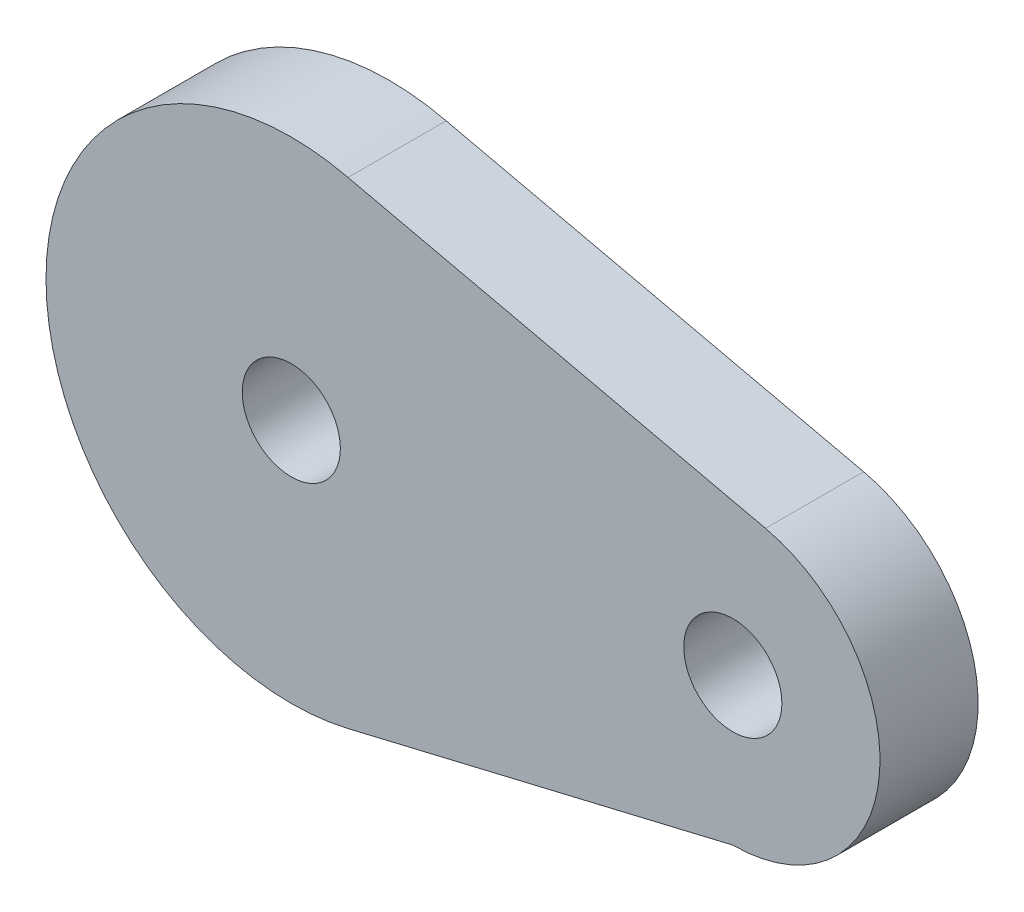
from build123d import *

# Parameters (mm, degrees)
SKETCH2_R           = 60
SKETCH2_R_2         = 5
BOSS_EXTRUDE1_DEPTH = 10
SKETCH3_R           = 5
CUT_EXTRUDE1_DEPTH  = 32
SKETCH4_R           = 81.078971207
CUT_EXTRUDE2_DEPTH  = 130


with BuildPart() as part:
    # Sketch2 → Boss-Extrude1 (new body)
    with BuildSketch(Plane.XY):
        Circle(SKETCH2_R)
        Circle(SKETCH2_R_2, mode=Mode.SUBTRACT)
    extrude(amount=BOSS_EXTRUDE1_DEPTH)

    # Sketch3 → Cut-Extrude1 (cut)
    with BuildSketch(Plane.XY.offset(10)):
        with Locations((45, 0)):
            Circle(SKETCH3_R)
    extrude(amount=-CUT_EXTRUDE1_DEPTH, mode=Mode.SUBTRACT)

    # Sketch4 → Cut-Extrude2 (cut)
    with BuildSketch(Plane(origin=(0, 0, 0), x_dir=(-1, 0, 0), z_dir=(0, 0, -1))):
        Circle(SKETCH4_R)
        with BuildLine():
            Line((-5.781451877, -24.322311037), (-45, -15))
            ThreePointArc((-45, -15), (-59.905960926, -1.676999964), (-48.332972793, 14.625022816))
            Line((-48.332972793, 14.625022816), (-5.781451877, 24.322311037))
            ThreePointArc((-5.781451877, 24.322311037), (25, 0), (-5.781451877, -24.322311037))
        make_face(mode=Mode.SUBTRACT)
    extrude(amount=-CUT_EXTRUDE2_DEPTH, mode=Mode.SUBTRACT)


solid = part.part
